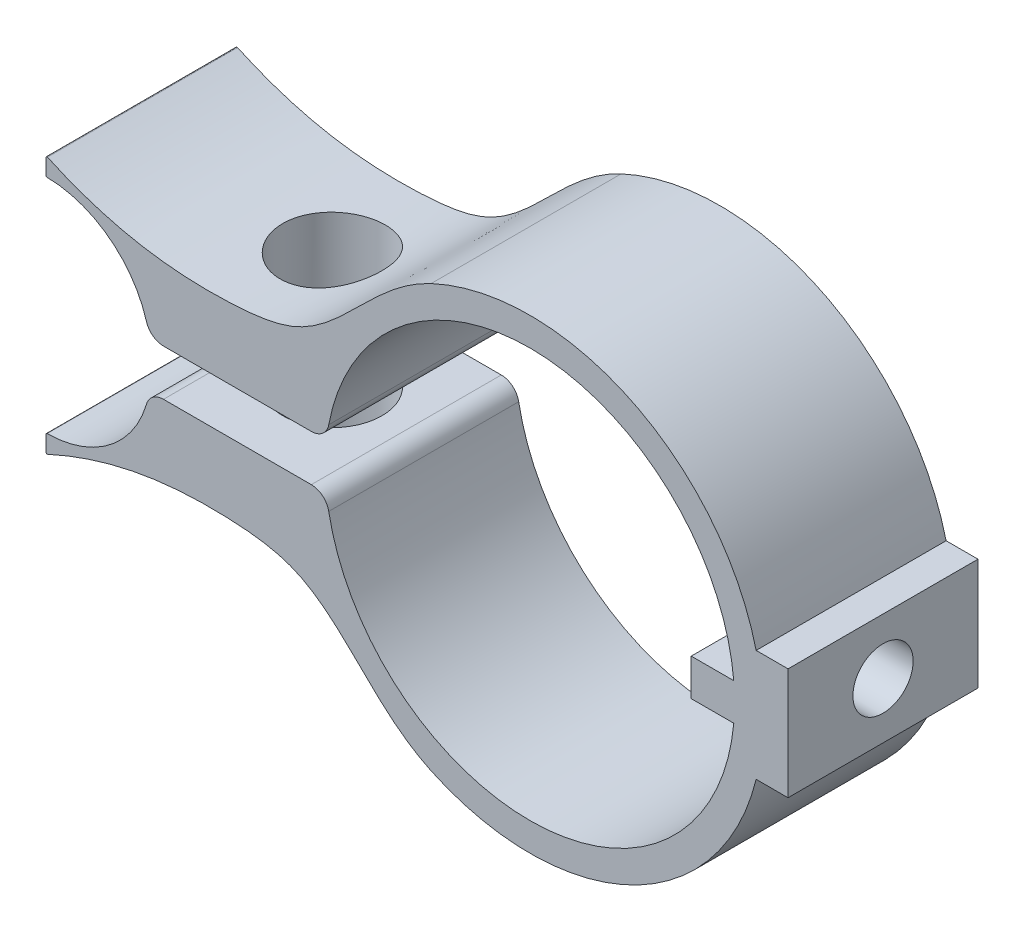
from build123d import *

# Parameters (mm, degrees)
BOSS_EXTRUDE1_DEPTH     = 13.6144
SKETCH2_R               = 2.159
CUT_EXTRUDE1_DEPTH      = 13.6144
SKETCH3_R               = 3.556
CUT_EXTRUDE2_DEPTH      = 19.3515001
CUT_EXTRUDE2_DEPTH_BACK = 16.0495001


with BuildPart() as part:
    # Sketch1 → Boss-Extrude1 (new body)
    with BuildSketch(Plane.XY):
        with BuildLine():
            Line((16.214274575, -4.0005), (18.500274575, -4.0005))
            Line((18.500274575, -4.0005), (18.500274575, 4.0005))
            Line((18.500274575, 4.0005), (16.214274575, 4.0005))
            ThreePointArc((16.214274575, 4.0005), (7.196292411, 15.070503501), (-7.081874578, 15.124607523))
            add(Edge.make_bspline(
                [(-34.576763977, 9.221111344), (-31.211698963, 7.674754632), (-26.936331304, 6.669830907), (-21.0372787, 6.68059468), (-14.050166755, 7.433841717), (-11.370908077, 13.116330795), (-7.081874578, 15.124607523)],
                knots=[0.003613688, 0.003613688, 0.003613688, 0.003613688, 0.34145961, 0.446329859, 0.584046692, 1, 1, 1, 1], degree=3))
            ThreePointArc((-34.576763977, 9.221111344), (-34.649703023, 9.216024047), (-34.684781665, 9.151872087))
            Line((-34.684781665, 9.151872087), (-34.684781665, 8.029296663))
            ThreePointArc((-34.684781665, 8.029296663), (-34.662733251, 7.975686535), (-34.609347392, 7.95310051))
            ThreePointArc((-34.609347392, 7.95310051), (-30.156588703, 6.433936835), (-27.482532193, 2.562975716))
            ThreePointArc((-27.482532193, 2.562975716), (-27.025031104, 1.904242693), (-26.264041893, 1.651))
            Line((-26.264041893, 1.651), (-15.668552621, 1.651))
            ThreePointArc((-15.668552621, 1.651), (-14.856977374, 1.944145038), (-14.420062373, 2.688250996))
            ThreePointArc((-14.420062373, 2.688250996), (0.690215059, 14.65225223), (14.608914388, 1.3208))
            Line((14.608914388, 1.3208), (11.560914388, 1.3208))
            Line((11.560914388, 1.3208), (11.560914388, -1.3208))
            Line((11.560914388, -1.3208), (14.608914388, -1.3208))
            ThreePointArc((14.608914388, -1.3208), (0.690215059, -14.65225223), (-14.420062373, -2.688250996))
            ThreePointArc((-14.420062373, -2.688250996), (-14.856977374, -1.944145038), (-15.668552621, -1.651))
            Line((-15.668552621, -1.651), (-26.264041893, -1.651))
            ThreePointArc((-26.264041893, -1.651), (-27.025031104, -1.904242693), (-27.482532193, -2.562975716))
            ThreePointArc((-27.482532193, -2.562975716), (-30.156588703, -6.433936835), (-34.609347392, -7.95310051))
            ThreePointArc((-34.609347392, -7.95310051), (-34.662733251, -7.975686535), (-34.684781665, -8.029296663))
            Line((-34.684781665, -8.029296663), (-34.684781665, -9.151872087))
            ThreePointArc((-34.684781665, -9.151872087), (-34.649703023, -9.216024047), (-34.576763977, -9.221111344))
            add(Edge.make_bspline(
                [(-34.576763977, -9.221111344), (-31.211698963, -7.674754632), (-26.936331304, -6.669830907), (-21.0372787, -6.68059468), (-14.050166755, -7.433841717), (-11.370908077, -13.116330795), (-7.081874578, -15.124607523)],
                knots=[0.003613688, 0.003613688, 0.003613688, 0.003613688, 0.34145961, 0.446329859, 0.584046692, 1, 1, 1, 1], degree=3))
            ThreePointArc((-7.081874578, -15.124607523), (7.196292411, -15.070503501), (16.214274575, -4.0005))
        make_face()
    extrude(amount=BOSS_EXTRUDE1_DEPTH)

    # Sketch2 → Cut-Extrude1 (cut)
    with BuildSketch(Plane(origin=(18.500274575, 0, 0), x_dir=(0, 0, -1), z_dir=(1, 0, 0))):
        with Locations((-6.8072, 0)):
            Circle(SKETCH2_R)
    extrude(amount=-CUT_EXTRUDE1_DEPTH, mode=Mode.SUBTRACT)

    # Sketch3 → Cut-Extrude2 (cut, two sides)
    with BuildSketch(Plane.XZ.offset(-1.651)) as cut_extrude2_sk:
        with Locations((-20.966297257, 6.8072)):
            Circle(SKETCH3_R)
    extrude(amount=CUT_EXTRUDE2_DEPTH, mode=Mode.SUBTRACT)
    extrude(cut_extrude2_sk.sketch, amount=-CUT_EXTRUDE2_DEPTH_BACK, mode=Mode.SUBTRACT)


solid = part.part
